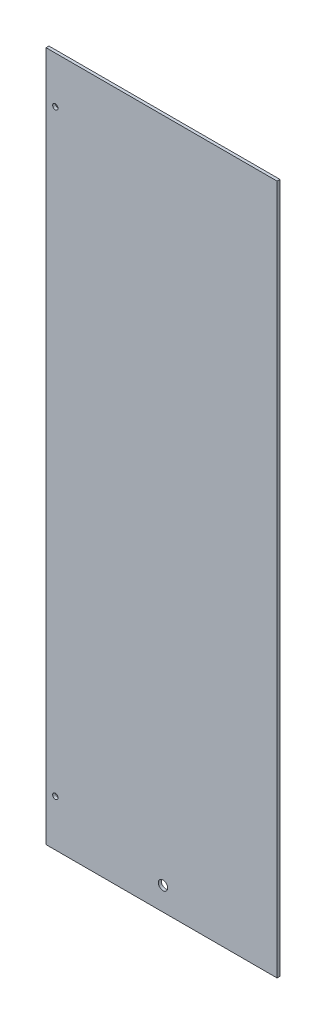
from build123d import *

# Parameters (mm, degrees)
SKETCH1_W        = 126.0475
SKETCH1_H        = 376.555
MAIN_PLATE_DEPTH = 1.5875
SKETCH2_R        = 1.4605
BOLT_HOLES_DEPTH = 6.35
LPATTERN1_COUNT  = 2
LPATTERN1_PITCH  = 325.755
SKETCH3_R        = 2.54
WIRE_HOLE_DEPTH  = 6.35


with BuildPart() as part:
    # Sketch1 → Main Plate (new body)
    with BuildSketch(Plane.XY):
        with Locations((63.02375, 188.2775)):
            Rectangle(SKETCH1_W, SKETCH1_H)
    extrude(amount=MAIN_PLATE_DEPTH)

    # Sketch2 → Bolt Holes (cut)
    with BuildSketch(Plane.XY.offset(1.5875)):
        with Locations((5.08, 351.155)):
            Circle(SKETCH2_R)
    bolt_holes = extrude(amount=-BOLT_HOLES_DEPTH, mode=Mode.SUBTRACT)

    # LPattern1: Bolt Holes ×2
    with Locations(*[(0, -i * LPATTERN1_PITCH, 0) for i in range(1, LPATTERN1_COUNT)]):
        add(bolt_holes, mode=Mode.SUBTRACT)

    # Sketch3 → Wire Hole (cut)
    with BuildSketch(Plane.XY.offset(1.5875)):
        with Locations((63.8175, 12.7)):
            Circle(SKETCH3_R)
    extrude(amount=-WIRE_HOLE_DEPTH, mode=Mode.SUBTRACT)


solid = part.part
